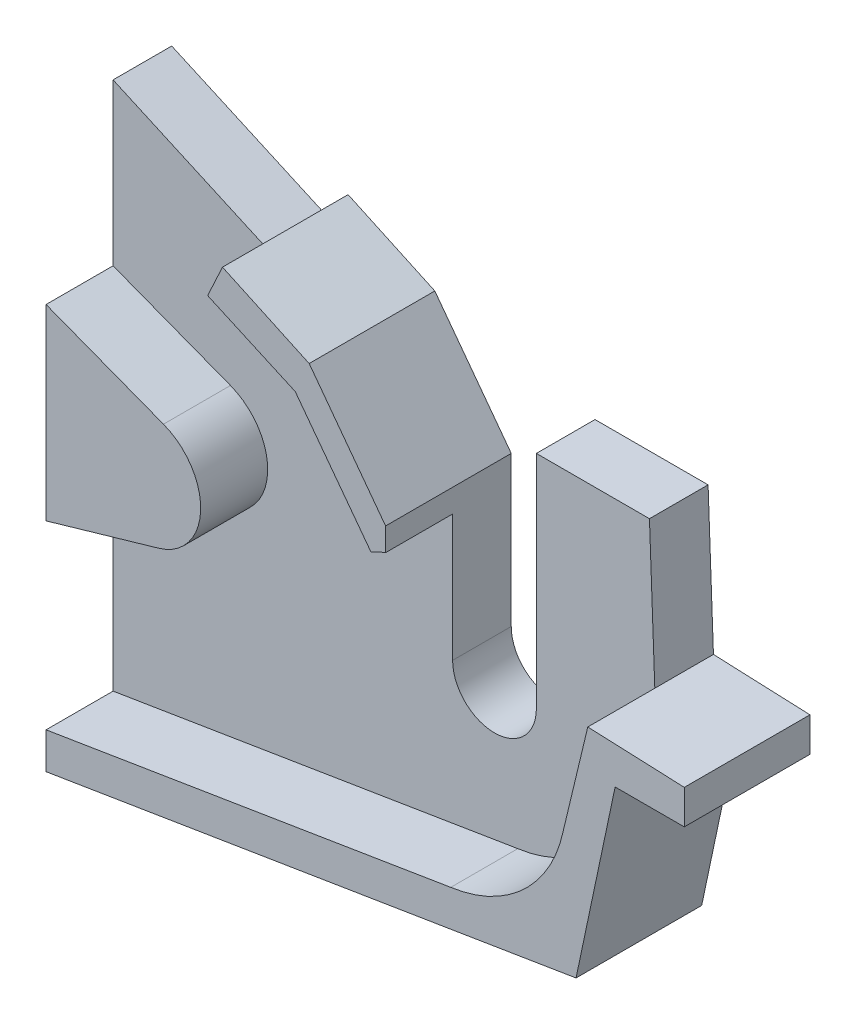
from build123d import *

# Parameters (mm, degrees)
BOSS_EXTRUDE2_DEPTH = 7
BOSS_EXTRUDE3_DEPTH = 15


with BuildPart() as part:
    # Sketch1 → Boss-Extrude2 (new body)
    with BuildSketch(Plane.XY):
        with BuildLine():
            Line((-41.446212302, -25.123400981), (21.822672825, -14.817519442))
            Line((21.822672825, -14.817519442), (26.489801196, 7.266810726))
            Line((26.489801196, 7.266810726), (34.744303123, 7.266810726))
            Line((34.744303123, 7.266810726), (34.744303123, 11.354641566))
            Line((34.744303123, 11.354641566), (23.2245968, 11.838054321))
            Line((23.2245968, 11.838054321), (22.586170837, 29.052034329))
            Line((22.586170837, 29.052034329), (9.086170837, 29.052034329))
            Line((9.086170837, 29.052034329), (9.086170837, 2.654622308))
            ThreePointArc((9.086170837, 2.654622308), (4.086170837, -2.345377692), (-0.913829163, 2.654622308))
            Line((-0.913829163, 2.654622308), (-0.913829163, 20.550462038))
            Line((-0.913829163, 20.550462038), (-10.036820206, 32.783811613))
            Line((-10.036820206, 32.783811613), (-20.38656022, 37.570023616))
            Line((-20.38656022, 37.570023616), (-22.155090004, 33.745741812))
            Line((-22.155090004, 33.745741812), (-41.446212302, 42.4049295))
            Line((-41.446212302, 42.4049295), (-41.446212302, -25.123400981))
        make_face()
    extrude(amount=BOSS_EXTRUDE2_DEPTH)

    # Sketch1_7 → Boss-Extrude3 (add)
    with BuildSketch(Plane.XY):
        with BuildLine():
            Line((-41.446212302, -20.792174742), (-41.446212302, -25.123400981))
            Line((-41.446212302, -25.123400981), (21.822672825, -14.817519442))
            Line((21.822672825, -14.817519442), (26.489801196, 7.266810726))
            Line((26.489801196, 7.266810726), (34.744303123, 7.266810726))
            Line((34.744303123, 7.266810726), (34.744303123, 11.354641566))
            Line((34.744303123, 11.354641566), (23.2245968, 11.838054321))
            Line((23.2245968, 11.838054321), (20.289273371, -0.393165966))
            ThreePointArc((20.289273371, -0.393165966), (15.564402865, -8.784041973), (6.869125611, -12.922079544))
            Line((6.869125611, -12.922079544), (-41.446212302, -20.792174742))
        make_face()
        with BuildLine():
            Line((-41.446212302, 0.807049614), (-27.991340604, 4.708206285))
            ThreePointArc((-27.991340604, 4.708206285), (-22.99414619, 11.058923492), (-27.430483413, 17.813364482))
            Line((-27.430483413, 17.813364482), (-41.446212302, 23.180975488))
            Line((-41.446212302, 23.180975488), (-41.446212302, 0.807049614))
        make_face()
        with BuildLine():
            Line((-11.698348753, 29.052034329), (-2.67291579, 17.003015737))
            ThreePointArc((-2.67291579, 17.003015737), (-1.805237347, 17.421962776), (-0.913829163, 17.787713989))
            Line((-0.913829163, 17.787713989), (-0.913829163, 20.550462038))
            Line((-0.913829163, 20.550462038), (-10.036820206, 32.783811613))
            Line((-10.036820206, 32.783811613), (-20.38656022, 37.570023616))
            Line((-20.38656022, 37.570023616), (-22.155090004, 33.745741812))
            Line((-22.155090004, 33.745741812), (-11.698348753, 29.052034329))
        make_face()
    extrude(amount=BOSS_EXTRUDE3_DEPTH)


solid = part.part
